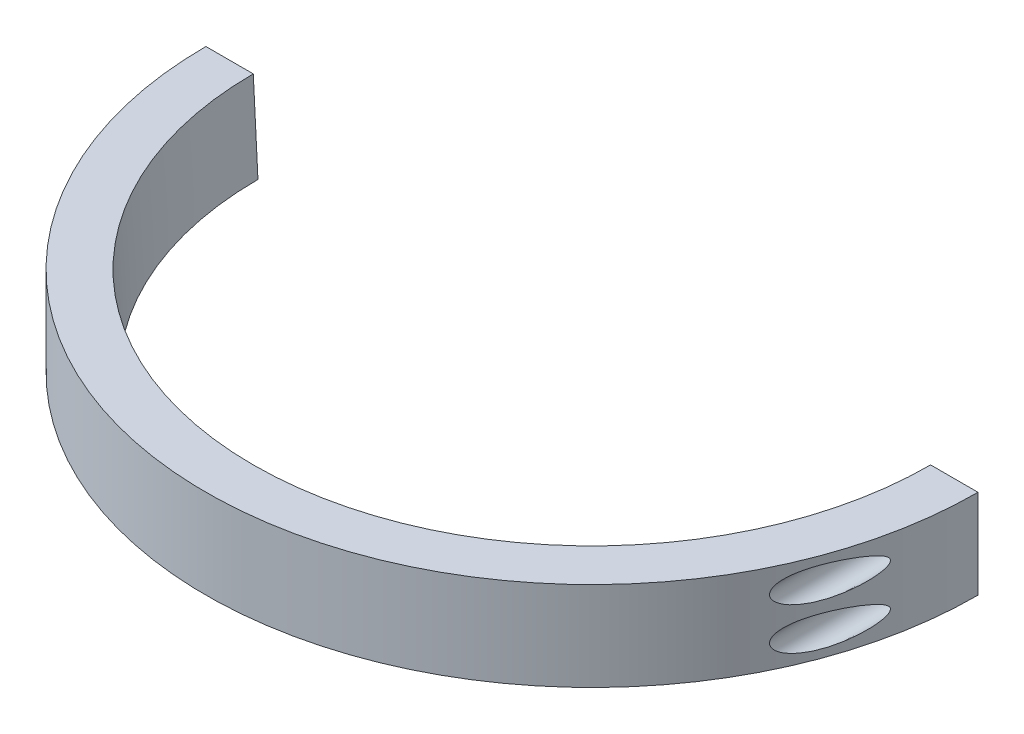
from build123d import *

# Parameters (mm, degrees)
REVOLVE2_ANGLE                 = 180
CBORE_FOR_M2_SHCS1_D           = 2.2
CBORE_FOR_M2_SHCS1_CBORE_D     = 4.4
CBORE_FOR_M2_SHCS1_CBORE_DEPTH = 50
SKETCH13_R                     = 1.65
CUT_EXTRUDE2_DEPTH             = 100


with BuildPart() as part:
    # Sketch3 → Revolve2 (revolve)
    with BuildSketch(Plane.XY):
        Polygon((48.25, 0), (47.584421203, -12.7), (55, -12.7), (55, 0), align=None)
    revolve(axis=Axis((0, 50.355486862, 0), (0, -1, 0)), revolution_arc=REVOLVE2_ANGLE)

    # CBORE for M2 SHCS1 (through all)
    with Locations(Plane.XY.offset(55)):
        with Locations((51.625, -3.35), (51.625, -9.35)):
            cbore_for_m2_shcs1 = CounterBoreHole(CBORE_FOR_M2_SHCS1_D / 2, CBORE_FOR_M2_SHCS1_CBORE_D / 2, CBORE_FOR_M2_SHCS1_CBORE_DEPTH)

    # Mirror1: CBORE for M2 SHCS1 across plane
    add(cbore_for_m2_shcs1.mirror(Plane(origin=(0, 0, 0), x_dir=(0, 0, 1), z_dir=(1, 0, 0))), mode=Mode.SUBTRACT)

    # Sketch13 → Cut-Extrude2 (cut, symmetric)
    with BuildSketch(Plane(origin=(0, 0, 0), x_dir=(0.707106781, 0, 0.707106781), z_dir=(-0.707106781, 0, 0.707106781))):
        with Locations((0, -6.35)):
            Circle(SKETCH13_R)
    extrude(amount=CUT_EXTRUDE2_DEPTH, both=True, mode=Mode.SUBTRACT)


solid = part.part
